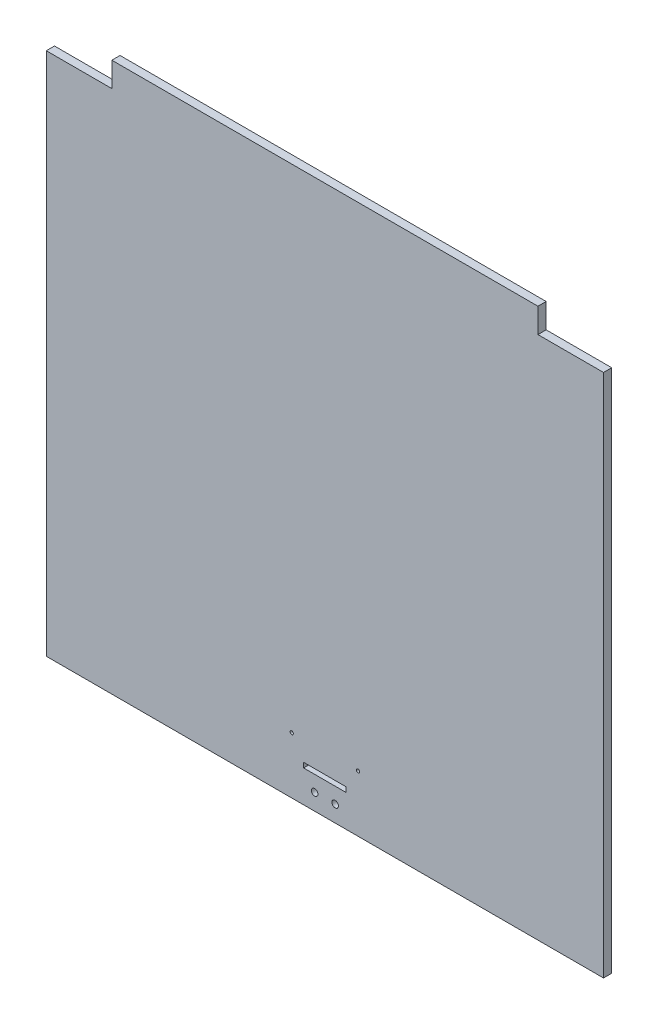
from build123d import *

# Parameters (mm, degrees)
ESQUISSE1_W             = 680
ESQUISSE1_H             = 670
BOSS_EXTRU_1_DEPTH      = 10
ESQUISSE2_W             = 80
ESQUISSE2_H             = 30
ENL_V_MAT_EXTRU_1_DEPTH = 11
ESQUISSE3_W             = 52
ESQUISSE3_H             = 6
ENL_V_MAT_EXTRU_2_DEPTH = 11
ESQUISSE4_R             = 4
ENL_V_MAT_EXTRU_3_DEPTH = 11
ESQUISSE5_R             = 2
ENL_V_MAT_EXTRU_4_DEPTH = 11


with BuildPart() as part:
    # Esquisse1 → Boss.-Extru.1 (new body)
    with BuildSketch(Plane.XY):
        Rectangle(ESQUISSE1_W, ESQUISSE1_H)
    extrude(amount=BOSS_EXTRU_1_DEPTH)

    # Esquisse2 → Enlèv. mat.-Extru.1 (cut, through all)
    with BuildSketch(Plane.XY.offset(10)):
        with Locations((-300, 320)):
            Rectangle(ESQUISSE2_W, ESQUISSE2_H)
        with Locations((300, 320)):
            Rectangle(ESQUISSE2_W, ESQUISSE2_H)
    extrude(amount=-ENL_V_MAT_EXTRU_1_DEPTH, mode=Mode.SUBTRACT)

    # Esquisse3 → Enlèv. mat.-Extru.2 (cut, through all)
    with BuildSketch(Plane.XY.offset(10)):
        with Locations((0, -293)):
            Rectangle(ESQUISSE3_W, ESQUISSE3_H)
    extrude(amount=-ENL_V_MAT_EXTRU_2_DEPTH, mode=Mode.SUBTRACT)

    # Esquisse4 → Enlèv. mat.-Extru.3 (cut, through all)
    with BuildSketch(Plane.XY.offset(10)):
        with Locations((-12.5, -315)):
            Circle(ESQUISSE4_R)
        with Locations((12.5, -315)):
            Circle(ESQUISSE4_R)
    extrude(amount=-ENL_V_MAT_EXTRU_3_DEPTH, mode=Mode.SUBTRACT)

    # Esquisse5 → Enlèv. mat.-Extru.4 (cut, through all)
    with BuildSketch(Plane.XY.offset(10)):
        with Locations((-40.5, -266)):
            Circle(ESQUISSE5_R)
        with Locations((40.5, -266)):
            Circle(ESQUISSE5_R)
    extrude(amount=-ENL_V_MAT_EXTRU_4_DEPTH, mode=Mode.SUBTRACT)


solid = part.part
